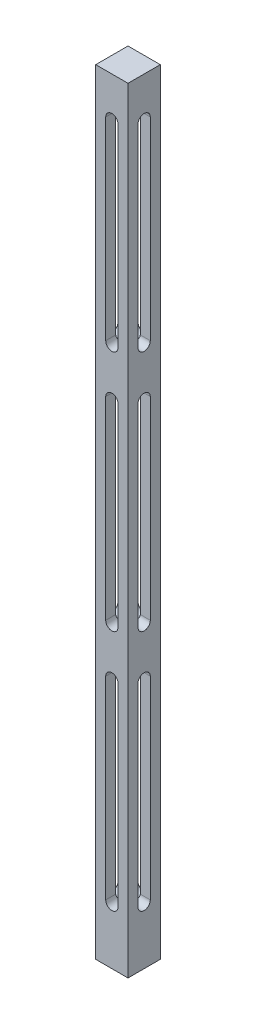
from build123d import *

# Parameters (mm, degrees)
SKETCH1_W           = 12.7
SKETCH1_H           = 12.7
BOSS_EXTRUDE1_DEPTH = 304.8
CUT_EXTRUDE1_DEPTH  = 13.7
CUT_EXTRUDE2_DEPTH  = 13.7
LPATTERN1_COUNT     = 3
LPATTERN1_PITCH     = 95.25


with BuildPart() as part:
    # Sketch1 → Boss-Extrude1 (new body)
    with BuildSketch(Plane(origin=(0, 0, 0), x_dir=(1, 0, 0), z_dir=(0, 1, 0))):
        Rectangle(SKETCH1_W, SKETCH1_H)
    extrude(amount=BOSS_EXTRUDE1_DEPTH)

    # Sketch2 → Cut-Extrude1 (cut, through all)
    with BuildSketch(Plane(origin=(0, 0, -6.35), x_dir=(-1, 0, 0), z_dir=(0, 0, -1))):
        with BuildLine():
            Line((-2.413, 288.925), (-2.413, 212.725))
            ThreePointArc((-2.413, 212.725), (0, 210.312), (2.413, 212.725))
            Line((2.413, 212.725), (2.413, 288.925))
            ThreePointArc((2.413, 288.925), (0, 291.338), (-2.413, 288.925))
        make_face()
    cut_extrude1 = extrude(amount=-CUT_EXTRUDE1_DEPTH, mode=Mode.SUBTRACT)

    # Sketch3 → Cut-Extrude2 (cut, through all)
    with BuildSketch(Plane(origin=(6.35, 0, 0), x_dir=(0, 0, -1), z_dir=(1, 0, 0))):
        with BuildLine():
            Line((-2.413, 288.925), (-2.413, 212.725))
            ThreePointArc((-2.413, 212.725), (0, 210.312), (2.413, 212.725))
            Line((2.413, 212.725), (2.413, 288.925))
            ThreePointArc((2.413, 288.925), (0, 291.338), (-2.413, 288.925))
        make_face()
    cut_extrude2 = extrude(amount=-CUT_EXTRUDE2_DEPTH, mode=Mode.SUBTRACT)

    # LPattern1: Cut-Extrude1, Cut-Extrude2 ×3
    with Locations(*[(0, -i * LPATTERN1_PITCH, 0) for i in range(1, LPATTERN1_COUNT)]):
        add(cut_extrude1, mode=Mode.SUBTRACT)
        add(cut_extrude2, mode=Mode.SUBTRACT)


solid = part.part
